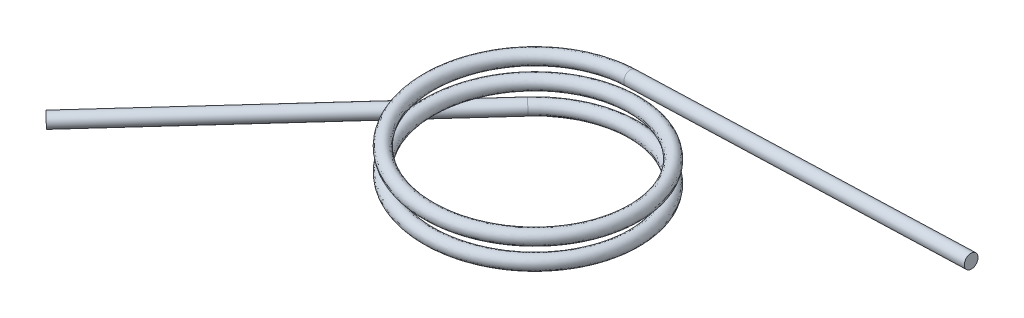
from build123d import *

# Parameters (mm, degrees)
SWEEP1_PITCH        = 6.477
SWEEP1_HEIGHT       = 13.763625
SWEEP1_RADIUS       = 30.607
SWEEP1_PROFILE_R    = 2.032
SKETCH15_R          = 2.032
BOSS_EXTRUDE1_DEPTH = 101.6
SKETCH24_R          = 2.032
BOSS_EXTRUDE2_DEPTH = 101.6


with BuildPart() as part:
    # Sweep1: sweep along a helix
    with BuildLine() as sweep1_path:
        Helix(SWEEP1_PITCH, SWEEP1_HEIGHT, SWEEP1_RADIUS, center=(0, 0, 0), direction=(0, -1, 0), lefthand=True)
    # Sweep1 profile (on start of the path) → Sweep1 (sweep)
    with BuildSketch(Plane(origin=(0, 0, -30.607), x_dir=(0.03366100544590081, -0.9994333077861529, 0), z_dir=(-0.9994333077861529, -0.03366100544590081, 8.785336148508286e-14))):
        Circle(SWEEP1_PROFILE_R)
    sweep(path=sweep1_path.line, is_frenet=True)


with BuildPart() as boss_extrude1_tool:
    # Sketch15 → Boss-Extrude1 (new body)
    with BuildSketch(Plane(origin=(-0.327432778, -0.015595886, 0.32743225), x_dir=(-0.6869140231965883, -0.20659395325851165, -0.6967553826221201), z_dir=(-0.7067066389601182, -0.033661005445922765, 0.7067054995980029))):
        with Locations(Location((32.789583515, 7.132635642, 0), (0, 0, 348.070316718))):
            Circle(SKETCH15_R)
    extrude(amount=BOSS_EXTRUDE1_DEPTH)


with BuildPart() as part_1:
    add(part.part)


with BuildPart() as part_2:
    # Boss-Extrude1: joined with boss_extrude1_tool
    add(part_1.part.fuse(boss_extrude1_tool.part, tol=0.00001))

    # Sketch24 → Boss-Extrude2 (add)
    with BuildSketch(Plane(origin=(0, 0, 0), x_dir=(0.006123856293887763, -0.1818242168092016, -0.9833119812988208), z_dir=(0.9994333077861522, 0.033661005445922494, -7.966717563423487e-15))):
        with Locations(Location((30.096229812, 5.568249287, 0), (0, 0, 100.482040539))):
            Circle(SKETCH24_R)
    extrude(amount=BOSS_EXTRUDE2_DEPTH)


solid = part_2.part
